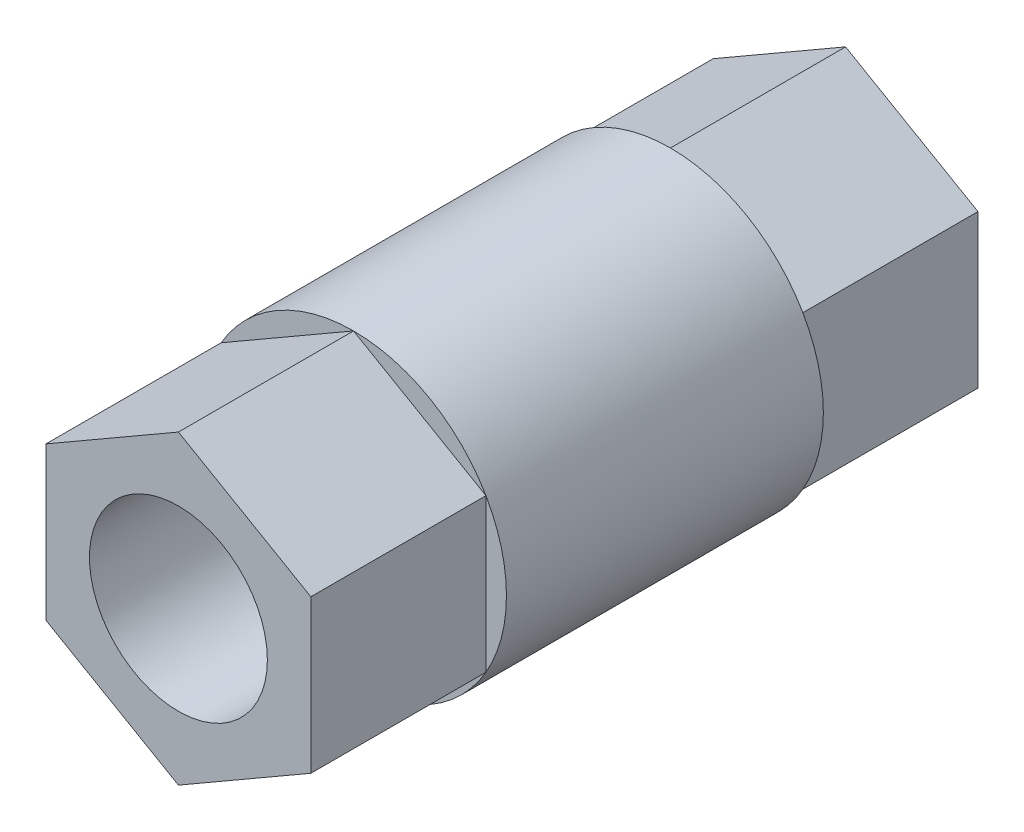
from build123d import *

# Parameters (mm, degrees)
SKETCH1_R           = 11
SKETCH1_R_2         = 6.4
BOSS_EXTRUDE1_DEPTH = 11.4
SKETCH1_3_R         = 6.4
BOSS_EXTRUDE2_DEPTH = 24


with BuildPart() as part:
    # Sketch1 → Boss-Extrude1 (new, symmetric)
    with BuildSketch(Plane.XY):
        Circle(SKETCH1_R)
        Circle(SKETCH1_R_2, mode=Mode.SUBTRACT)
    extrude(amount=BOSS_EXTRUDE1_DEPTH, both=True)

    # Sketch1_3 → Boss-Extrude2 (add, symmetric)
    with BuildSketch(Plane.XY):
        Polygon((-9.526279442, -5.5), (0, -11), (9.526279442, -5.5), (9.526279442, 5.5), (0, 11), (-9.526279442, 5.5), align=None)
        Circle(SKETCH1_3_R, mode=Mode.SUBTRACT)
    extrude(amount=BOSS_EXTRUDE2_DEPTH, both=True)


solid = part.part
